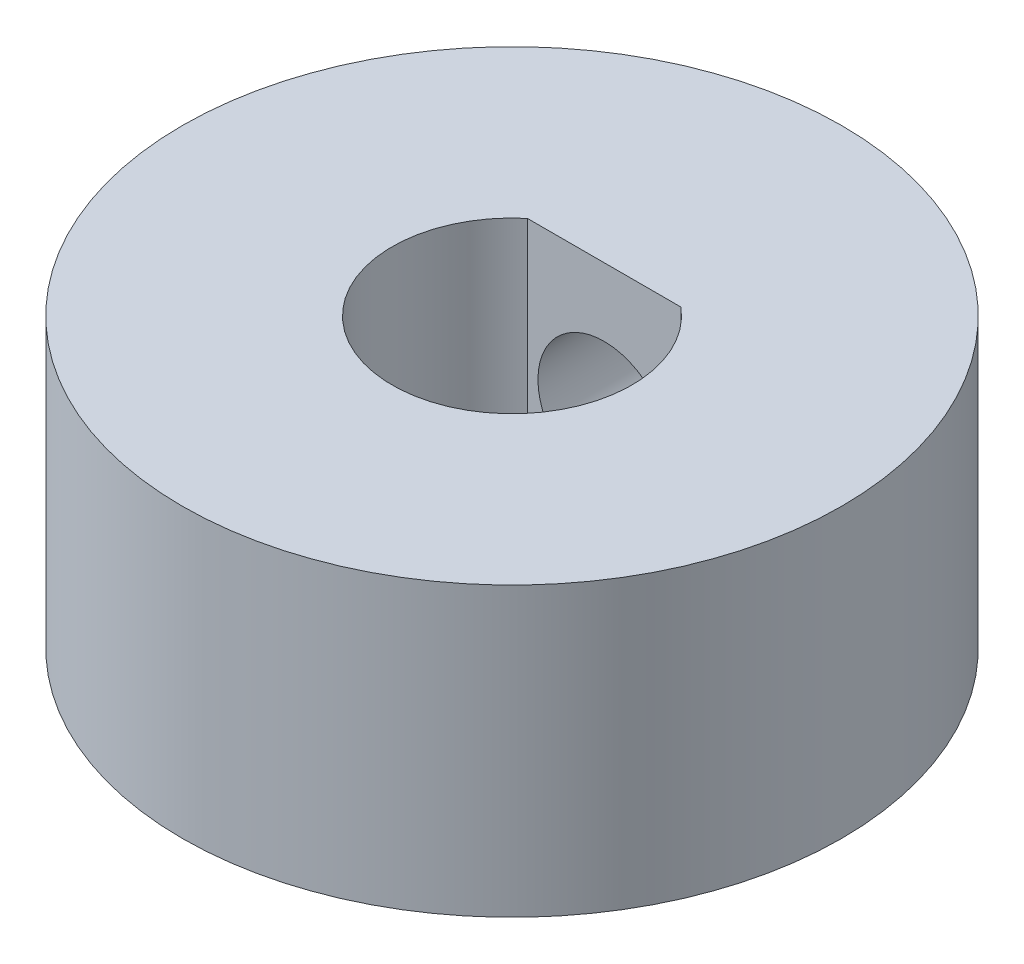
from build123d import *

# Parameters (mm, degrees)
SKETCH1_R           = 8.73125
BOSS_EXTRUDE1_DEPTH = 7.62
SKETCH2_R           = 2.7686
CUT_EXTRUDE1_DEPTH  = 3.81
CUT_EXTRUDE2_REACH  = 15.653
SKETCH3_R           = 1.7526


with BuildPart() as part:
    # Sketch1 → Boss-Extrude1 (new body)
    with BuildSketch(Plane(origin=(0, 0, 0), x_dir=(1, 0, 0), z_dir=(0, 1, 0))):
        Circle(SKETCH1_R)
        with BuildLine():
            Line((-2.032, 2.439590334), (2.032, 2.439590334))
            ThreePointArc((2.032, 2.439590334), (0, -3.175), (-2.032, 2.439590334))
        make_face(mode=Mode.SUBTRACT)
    extrude(amount=BOSS_EXTRUDE1_DEPTH)

    # Sketch2 → Cut-Extrude1 (cut)
    with BuildSketch(Plane(origin=(0, 0, -8.73125), x_dir=(-1, 0, 0), z_dir=(0, 0, -1))):
        with Locations((0, 4.064)):
            Circle(SKETCH2_R)
    extrude(amount=-CUT_EXTRUDE1_DEPTH, mode=Mode.SUBTRACT)

    # Sketch3 → Cut-Extrude2 (cut, up to next)
    with BuildSketch(Plane(origin=(0, 0, -4.92125), x_dir=(-1, 0, 0), z_dir=(0, 0, -1)), mode=Mode.PRIVATE) as cut_extrude2_sk1:
        with Locations((0, 4.064)):
            Circle(SKETCH3_R)
    cut_extrude2_tool1 = extrude(cut_extrude2_sk1.sketch, amount=-CUT_EXTRUDE2_REACH, mode=Mode.PRIVATE) & part.part
    add(cut_extrude2_tool1.solids().sort_by_distance((0, 4.064, -4.92125))[0], mode=Mode.SUBTRACT)


solid = part.part
